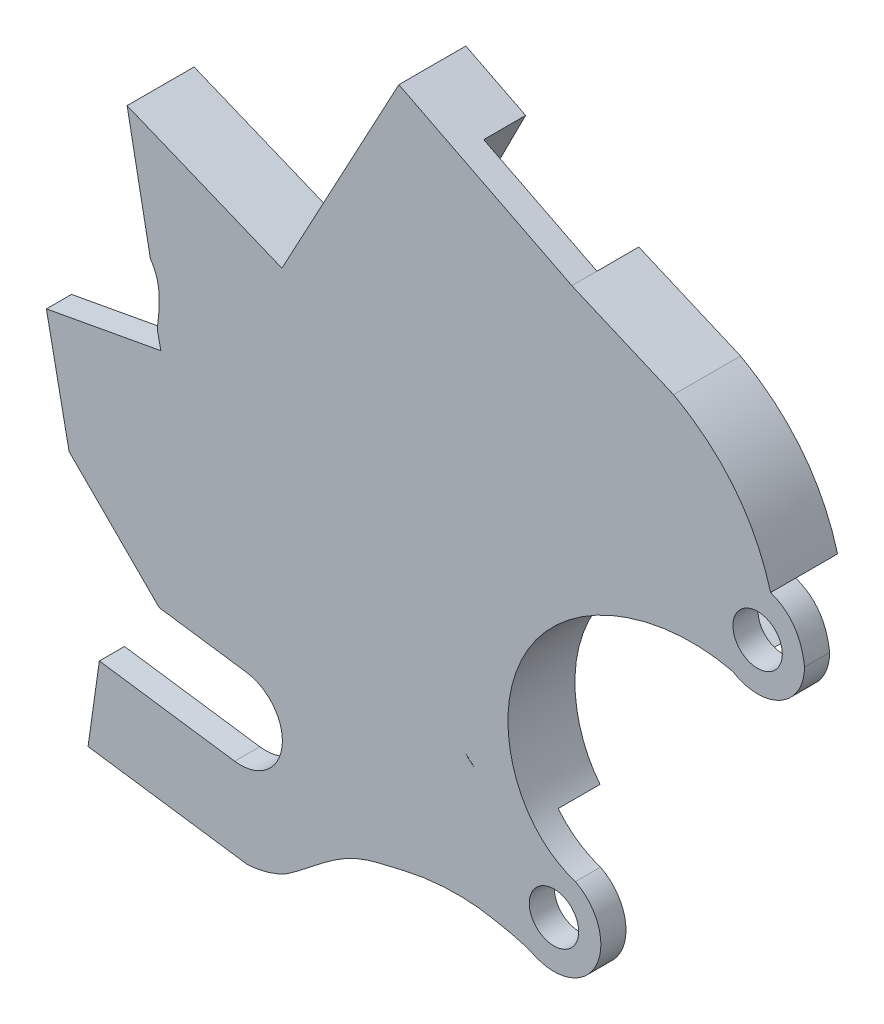
from build123d import *

# Parameters (mm, degrees)
SKETCH1_R           = 2.95
BOSS_EXTRUDE1_DEPTH = 3
BOSS_EXTRUDE2_DEPTH = 5


with BuildPart() as part:
    # Sketch1 → Boss-Extrude1 (new body)
    with BuildSketch(Plane.XY):
        with BuildLine():
            Line((885.497024513, 715.28442401), (895.908879778, 713.809889116))
            ThreePointArc((895.908879778, 713.809889116), (898.983055968, 712.137585236), (900.20777192, 708.859288368))
            ThreePointArc((900.20777192, 708.859288368), (898.486068788, 705.08400432), (894.506664062, 703.908687619))
            Line((894.506664062, 703.908687619), (884.094808796, 705.383222513))
            Line((884.094808796, 705.383222513), (878.346250622, 706.197337711))
            Line((878.346250622, 706.197337711), (876.997082066, 696.670708126))
            Line((876.997082066, 696.670708126), (895.908879778, 693.992404893))
            add(Edge.make_bspline(
                [(900.677927067, 695.342407163), (898.457126816, 694.079685625), (895.908879778, 693.992404893)],
                knots=[0, 0, 0, 1, 1, 1], degree=2))
            add(Edge.make_bspline(
                [(930.303509436, 701.731720607), (928.908582173, 702.34252613), (926.781801367, 702.782198876), (923.63873322, 703.361886212), (920.373840467, 703.533963776), (916.516565694, 703.165924681), (912.976990493, 702.279499081), (910.064088954, 701.602336705), (905.830375081, 699.661772542), (903.0609571, 696.933209558), (900.677927067, 695.342407163)],
                knots=[0.004488794, 0.004488794, 0.004488794, 0.004488794, 0.145803582, 0.207360666, 0.303386503, 0.45068914, 0.567818533, 0.644736883, 0.729998004, 1, 1, 1, 1], degree=3))
            ThreePointArc((930.303509436, 701.731720607), (927.38815206, 708.73395718), (934.125166842, 712.218674883))
            add(Edge.make_bspline(
                [(933.598769325, 712.474255657), (933.770803606, 712.384728048), (933.946269783, 712.299475151), (934.125166842, 712.218674883)],
                knots=[0.968386538, 0.968386538, 0.968386538, 0.968386538, 0.979155732, 0.979155732, 0.979155732, 0.979155732], degree=3))
            add(Edge.make_bspline(
                [(933.598769325, 712.474255657), (932.863128241, 712.728484515), (932.108679796, 712.935750272), (931.427331761, 713.125013615)],
                knots=[0.431721619, 0.431721619, 0.431721619, 0.431721619, 1, 1, 1, 1], degree=3))
            add(Edge.make_bspline(
                [(931.427331761, 713.125013615), (930.546746449, 713.380667415), (929.689085983, 713.709529693)],
                knots=[0, 0, 0, 1, 1, 1], degree=2))
            add(Edge.make_bspline(
                [(929.689085983, 713.709529693), (927.346129531, 714.504567456), (925.260884801, 715.888407846), (923.339126934, 717.436789846)],
                knots=[0, 0, 0, 0, 0.798817264, 0.798817264, 0.798817264, 0.798817264], degree=3))
            ThreePointArc((923.339126934, 717.436789846), (922.603623657, 718.005046821), (921.916742519, 718.631206035))
            ThreePointArc((921.916742519, 718.631206035), (919.407335977, 722.353305124), (918.52549244, 726.754838356))
            add(Edge.make_bspline(
                [(918.52549244, 726.754838356), (918.425679492, 727.763570062), (918.578497465, 729.216671259), (919.206168772, 731.270115986), (919.925007076, 732.795418698), (920.573643508, 734.487553029), (921.241338856, 735.930326979), (921.952566954, 737.858963655), (922.639091181, 739.19947461), (923.362980623, 739.936482701)],
                knots=[0, 0, 0, 0, 0.212341479, 0.30426936, 0.451259731, 0.566828168, 0.685956156, 0.785785837, 1, 1, 1, 1], degree=3))
            add(Edge.make_bspline(
                [(923.362980623, 739.936482701), (924.073382877, 740.845756336), (925.862134636, 742.360255324), (929.039651151, 743.808436685), (935.736406856, 745.602453139), (941.631709135, 745.465615724), (946.171415762, 744.91451418)],
                knots=[0, 0, 0, 0, 0.142861717, 0.285902238, 0.429507083, 1, 1, 1, 1], degree=3))
            add(Edge.make_bspline(
                [(946.171415762, 744.91451418), (950.252989924, 744.731252909), (953.995609929, 742.945939827)],
                knots=[0, 0, 0, 1, 1, 1], degree=2))
            ThreePointArc((953.995609929, 742.945939827), (952.951765542, 751.592206148), (961.625003419, 750.803233951))
            add(Edge.make_bspline(
                [(958.523980603, 753.362886982), (960.591554286, 752.622649132), (961.625003419, 750.803233951)],
                knots=[0, 0, 0, 0.585819586, 0.585819586, 0.585819586], degree=2))
            add(Edge.make_bspline(
                [(934.778629473, 773.230527013), (934.45380595, 770.865818755), (935.594690673, 765.096373371), (944.406081317, 757.247029506), (952.925533915, 754.489007975), (958.523980603, 753.362886982)],
                knots=[0, 0, 0, 0, 0.212696239, 0.491716192, 1, 1, 1, 1], degree=3))
            Line((934.778629473, 773.230527013), (921.256910752, 780.078594478))
            Line((921.256910752, 780.078594478), (908.253791187, 754.403537076))
            Line((908.253791187, 754.403537076), (900.153140647, 738.699490733))
            ThreePointArc((900.153140647, 738.699490733), (892.542478866, 734.633266851), (886.038505046, 740.303775995))
            ThreePointArc((886.038505046, 740.303775995), (885.964108, 740.624051489), (885.903637207, 740.947245851))
            Line((885.903637207, 740.947245851), (885.690507065, 741.964114089))
            Line((885.690507065, 741.964114089), (872.020959777, 739.453246535))
            Line((872.020959777, 739.453246535), (874.735628343, 726.045820179))
            Line((874.735628343, 726.045820179), (885.497024513, 715.28442401))
        make_face()
        with BuildLine():
            Line((885.264353308, 743.997342314), (885.690507065, 741.964114089))
            Line((885.690507065, 741.964114089), (885.805090366, 741.985161128))
            ThreePointArc((885.805090366, 741.985161128), (893.301781588, 749.780081473), (900.998587409, 742.18269096))
            ThreePointArc((900.998587409, 742.18269096), (900.784201155, 740.390522996), (900.153140647, 738.699490733))
            Line((900.153140647, 738.699490733), (908.253791187, 754.403537076))
            Line((908.253791187, 754.403537076), (900.153140647, 757.723094445))
            Line((900.153140647, 757.723094445), (881.664505683, 765.299533417))
            Line((881.664505683, 765.299533417), (884.447893022, 750.825919253))
            add(Edge.make_bspline(
                [(884.447893022, 750.825919253), (885.896564624, 748.865855952), (885.518023401, 746.236814271), (885.264353308, 743.997342314)],
                knots=[0, 0, 0, 0, 1, 1, 1, 1], degree=3))
        make_face()
        with BuildLine():
            Line((885.805090366, 741.985161128), (885.690507065, 741.964114089))
            Line((885.690507065, 741.964114089), (885.903637207, 740.947245851))
            ThreePointArc((885.903637207, 740.947245851), (885.836540268, 741.464511202), (885.805090366, 741.985161128))
        make_face()
        with BuildLine():
            ThreePointArc((900.998587409, 742.18269096), (893.301781588, 749.780081473), (885.805090366, 741.985161128))
            ThreePointArc((885.805090366, 741.985161128), (885.836540268, 741.464511202), (885.903637207, 740.947245851))
            Line((885.903637207, 740.947245851), (886.038505046, 740.303775995))
            ThreePointArc((886.038505046, 740.303775995), (892.542478866, 734.633266851), (900.153140647, 738.699490733))
            ThreePointArc((900.153140647, 738.699490733), (900.784201155, 740.390522996), (900.998587409, 742.18269096))
        make_face()
        with BuildLine():
            Line((886.038505046, 740.303775995), (885.903637207, 740.947245851))
            ThreePointArc((885.903637207, 740.947245851), (885.964108, 740.624051489), (886.038505046, 740.303775995))
        make_face()
        with BuildLine():
            ThreePointArc((934.125166842, 712.218674883), (927.38815206, 708.73395718), (930.303509436, 701.731720607))
            add(Edge.make_bspline(
                [(930.436172356, 701.672583933), (930.392040469, 701.692609464), (930.347818605, 701.712318674), (930.303509436, 701.731720607)],
                knots=[0, 0, 0, 0, 0.004488794, 0.004488794, 0.004488794, 0.004488794], degree=3))
            ThreePointArc((930.436172356, 701.672583933), (935.728988911, 702.139184017), (938.249669512, 706.816554223))
            ThreePointArc((938.249669512, 706.816554223), (937.427530131, 709.737521171), (935.202509544, 711.800830276))
            add(Edge.make_bspline(
                [(934.125166842, 712.218674883), (934.471430292, 712.062282264), (934.830546981, 711.922570692), (935.202509544, 711.800830276)],
                knots=[0.979155732, 0.979155732, 0.979155732, 0.979155732, 1, 1, 1, 1], degree=3))
        make_face()
        with Locations((932.649669512, 706.816554223)):
            Circle(SKETCH1_R, mode=Mode.SUBTRACT)
        Polygon((900.153140647, 757.723094445), (908.253791187, 754.403537076), (921.256910752, 780.078594478), (914.119999733, 783.693079379), align=None)
        with BuildLine():
            add(Edge.make_bspline(
                [(933.598769325, 712.474255657), (932.863128241, 712.728484515), (932.108679796, 712.935750272), (931.427331761, 713.125013615)],
                knots=[0.431721619, 0.431721619, 0.431721619, 0.431721619, 1, 1, 1, 1], degree=3))
            add(Edge.make_bspline(
                [(930.146714251, 715.330936325), (931.080114022, 714.16810034), (932.230969204, 713.186066545), (933.598769325, 712.474255657)],
                knots=[0.882763457, 0.882763457, 0.882763457, 0.882763457, 0.968386538, 0.968386538, 0.968386538, 0.968386538], degree=3))
            ThreePointArc((930.146714251, 715.330936325), (926.574551452, 715.839576594), (923.339126934, 717.436789846))
            add(Edge.make_bspline(
                [(929.689085983, 713.709529693), (927.346129531, 714.504567456), (925.260884801, 715.888407846), (923.339126934, 717.436789846)],
                knots=[0, 0, 0, 0, 0.798817264, 0.798817264, 0.798817264, 0.798817264], degree=3))
            add(Edge.make_bspline(
                [(931.427331761, 713.125013615), (930.546746449, 713.380667415), (929.689085983, 713.709529693)],
                knots=[0, 0, 0, 1, 1, 1], degree=2))
        make_face()
        with BuildLine():
            ThreePointArc((923.339126934, 717.436789846), (926.574551452, 715.839576594), (930.146714251, 715.330936325))
            add(Edge.make_bspline(
                [(933.411194109, 737.64388575), (932.081362902, 736.468985383), (928.894343799, 732.838861644), (926.136429505, 724.767044697), (928.013551916, 717.988444931), (930.146714251, 715.330936325)],
                knots=[0.414107758, 0.414107758, 0.414107758, 0.414107758, 0.51449475, 0.687083176, 0.882763457, 0.882763457, 0.882763457, 0.882763457], degree=3))
            ThreePointArc((933.411194109, 737.64388575), (923.205334131, 735.976490422), (918.52549244, 726.754838356))
            ThreePointArc((918.52549244, 726.754838356), (919.407335977, 722.353305124), (921.916742519, 718.631206035))
            add(Edge.make_bspline(
                [(923.339126934, 717.436789846), (922.855130754, 717.82675103), (922.38150435, 718.227148893), (921.916742519, 718.631206035)],
                knots=[0.798817264, 0.798817264, 0.798817264, 0.798817264, 1, 1, 1, 1], degree=3))
        make_face()
        with BuildLine():
            Line((946.924849874, 768.032607795), (934.778629473, 773.230527013))
            add(Edge.make_bspline(
                [(934.778629473, 773.230527013), (934.45380595, 770.865818755), (935.594690673, 765.096373371), (944.406081317, 757.247029506), (952.925533915, 754.489007975), (958.523980603, 753.362886982)],
                knots=[0, 0, 0, 0, 0.212696239, 0.491716192, 1, 1, 1, 1], degree=3))
            add(Edge.make_bspline(
                [(958.523980603, 753.362886982), (955.780459312, 763.160081877), (946.924849874, 768.032607795)],
                knots=[0, 0, 0, 1, 1, 1], degree=2))
        make_face()
        with BuildLine():
            ThreePointArc((918.52549244, 726.754838356), (923.205334131, 735.976490422), (933.411194109, 737.64388575))
            add(Edge.make_bspline(
                [(953.995609929, 742.945939827), (947.067845638, 744.613045959), (938.896899075, 742.49048338), (933.411194109, 737.64388575)],
                knots=[0, 0, 0, 0, 0.414107758, 0.414107758, 0.414107758, 0.414107758], degree=3))
            add(Edge.make_bspline(
                [(946.171415762, 744.91451418), (950.252989924, 744.731252909), (953.995609929, 742.945939827)],
                knots=[0, 0, 0, 1, 1, 1], degree=2))
            add(Edge.make_bspline(
                [(923.362980623, 739.936482701), (924.073382877, 740.845756336), (925.862134636, 742.360255324), (929.039651151, 743.808436685), (935.736406856, 745.602453139), (941.631709135, 745.465615724), (946.171415762, 744.91451418)],
                knots=[0, 0, 0, 0, 0.142861717, 0.285902238, 0.429507083, 1, 1, 1, 1], degree=3))
            add(Edge.make_bspline(
                [(918.52549244, 726.754838356), (918.425679492, 727.763570062), (918.578497465, 729.216671259), (919.206168772, 731.270115986), (919.925007076, 732.795418698), (920.573643508, 734.487553029), (921.241338856, 735.930326979), (921.952566954, 737.858963655), (922.639091181, 739.19947461), (923.362980623, 739.936482701)],
                knots=[0, 0, 0, 0, 0.212341479, 0.30426936, 0.451259731, 0.566828168, 0.685956156, 0.785785837, 1, 1, 1, 1], degree=3))
        make_face()
        with BuildLine():
            ThreePointArc((961.625003419, 750.803233951), (952.951765542, 751.592206148), (953.995609929, 742.945939827))
            ThreePointArc((953.995609929, 742.945939827), (959.681113331, 742.791448126), (962.569400528, 747.691102571))
            add(Edge.make_bspline(
                [(961.625003419, 750.803233951), (962.355662482, 749.516888887), (962.569400528, 747.691102571)],
                knots=[0.585819586, 0.585819586, 0.585819586, 1, 1, 1], degree=2))
        make_face()
        with Locations((956.969400528, 747.691102571)):
            Circle(SKETCH1_R, mode=Mode.SUBTRACT)
    extrude(amount=BOSS_EXTRUDE1_DEPTH)

    # Sketch1_3 → Boss-Extrude2 (add)
    with BuildSketch(Plane.XY):
        with BuildLine():
            Line((885.264353308, 743.997342314), (885.690507065, 741.964114089))
            Line((885.690507065, 741.964114089), (885.805090366, 741.985161128))
            ThreePointArc((885.805090366, 741.985161128), (893.301781588, 749.780081473), (900.998587409, 742.18269096))
            ThreePointArc((900.998587409, 742.18269096), (900.784201155, 740.390522996), (900.153140647, 738.699490733))
            Line((900.153140647, 738.699490733), (908.253791187, 754.403537076))
            Line((908.253791187, 754.403537076), (900.153140647, 757.723094445))
            Line((900.153140647, 757.723094445), (881.664505683, 765.299533417))
            Line((881.664505683, 765.299533417), (884.447893022, 750.825919253))
            add(Edge.make_bspline(
                [(884.447893022, 750.825919253), (885.896564624, 748.865855952), (885.518023401, 746.236814271), (885.264353308, 743.997342314)],
                knots=[0, 0, 0, 0, 1, 1, 1, 1], degree=3))
        make_face()
        with BuildLine():
            ThreePointArc((900.998587409, 742.18269096), (893.301781588, 749.780081473), (885.805090366, 741.985161128))
            ThreePointArc((885.805090366, 741.985161128), (885.836540268, 741.464511202), (885.903637207, 740.947245851))
            Line((885.903637207, 740.947245851), (886.038505046, 740.303775995))
            ThreePointArc((886.038505046, 740.303775995), (892.542478866, 734.633266851), (900.153140647, 738.699490733))
            ThreePointArc((900.153140647, 738.699490733), (900.784201155, 740.390522996), (900.998587409, 742.18269096))
        make_face()
        Polygon((900.153140647, 757.723094445), (908.253791187, 754.403537076), (921.256910752, 780.078594478), (914.119999733, 783.693079379), align=None)
        with BuildLine():
            ThreePointArc((923.339126934, 717.436789846), (926.574551452, 715.839576594), (930.146714251, 715.330936325))
            add(Edge.make_bspline(
                [(933.411194109, 737.64388575), (932.081362902, 736.468985383), (928.894343799, 732.838861644), (926.136429505, 724.767044697), (928.013551916, 717.988444931), (930.146714251, 715.330936325)],
                knots=[0.414107758, 0.414107758, 0.414107758, 0.414107758, 0.51449475, 0.687083176, 0.882763457, 0.882763457, 0.882763457, 0.882763457], degree=3))
            ThreePointArc((933.411194109, 737.64388575), (923.205334131, 735.976490422), (918.52549244, 726.754838356))
            ThreePointArc((918.52549244, 726.754838356), (919.407335977, 722.353305124), (921.916742519, 718.631206035))
            add(Edge.make_bspline(
                [(923.339126934, 717.436789846), (922.855130754, 717.82675103), (922.38150435, 718.227148893), (921.916742519, 718.631206035)],
                knots=[0.798817264, 0.798817264, 0.798817264, 0.798817264, 1, 1, 1, 1], degree=3))
        make_face()
        with BuildLine():
            Line((946.924849874, 768.032607795), (934.778629473, 773.230527013))
            add(Edge.make_bspline(
                [(934.778629473, 773.230527013), (934.45380595, 770.865818755), (935.594690673, 765.096373371), (944.406081317, 757.247029506), (952.925533915, 754.489007975), (958.523980603, 753.362886982)],
                knots=[0, 0, 0, 0, 0.212696239, 0.491716192, 1, 1, 1, 1], degree=3))
            add(Edge.make_bspline(
                [(958.523980603, 753.362886982), (955.780459312, 763.160081877), (946.924849874, 768.032607795)],
                knots=[0, 0, 0, 1, 1, 1], degree=2))
        make_face()
        with BuildLine():
            ThreePointArc((918.52549244, 726.754838356), (923.205334131, 735.976490422), (933.411194109, 737.64388575))
            add(Edge.make_bspline(
                [(953.995609929, 742.945939827), (947.067845638, 744.613045959), (938.896899075, 742.49048338), (933.411194109, 737.64388575)],
                knots=[0, 0, 0, 0, 0.414107758, 0.414107758, 0.414107758, 0.414107758], degree=3))
            add(Edge.make_bspline(
                [(946.171415762, 744.91451418), (950.252989924, 744.731252909), (953.995609929, 742.945939827)],
                knots=[0, 0, 0, 1, 1, 1], degree=2))
            add(Edge.make_bspline(
                [(923.362980623, 739.936482701), (924.073382877, 740.845756336), (925.862134636, 742.360255324), (929.039651151, 743.808436685), (935.736406856, 745.602453139), (941.631709135, 745.465615724), (946.171415762, 744.91451418)],
                knots=[0, 0, 0, 0, 0.142861717, 0.285902238, 0.429507083, 1, 1, 1, 1], degree=3))
            add(Edge.make_bspline(
                [(918.52549244, 726.754838356), (918.425679492, 727.763570062), (918.578497465, 729.216671259), (919.206168772, 731.270115986), (919.925007076, 732.795418698), (920.573643508, 734.487553029), (921.241338856, 735.930326979), (921.952566954, 737.858963655), (922.639091181, 739.19947461), (923.362980623, 739.936482701)],
                knots=[0, 0, 0, 0, 0.212341479, 0.30426936, 0.451259731, 0.566828168, 0.685956156, 0.785785837, 1, 1, 1, 1], degree=3))
        make_face()
    extrude(amount=-BOSS_EXTRUDE2_DEPTH)


solid = part.part
